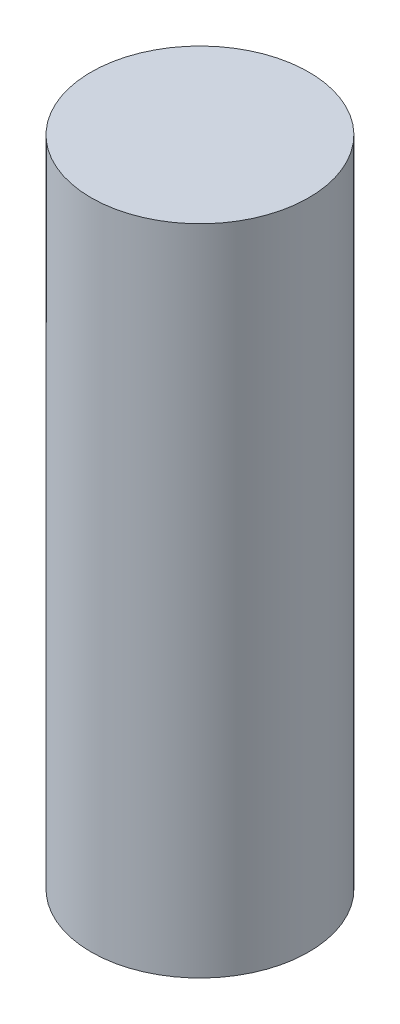
from build123d import *

# Parameters (mm, degrees)
SKETCH1_R           = 5
BOSS_EXTRUDE1_DEPTH = 15


with BuildPart() as part:
    # Sketch1 → Boss-Extrude1 (new body, symmetric)
    with BuildSketch(Plane(origin=(0, 0, 0), x_dir=(1, 0, 0), z_dir=(0, 1, 0))):
        Circle(SKETCH1_R)
    extrude(amount=BOSS_EXTRUDE1_DEPTH, both=True)


solid = part.part
